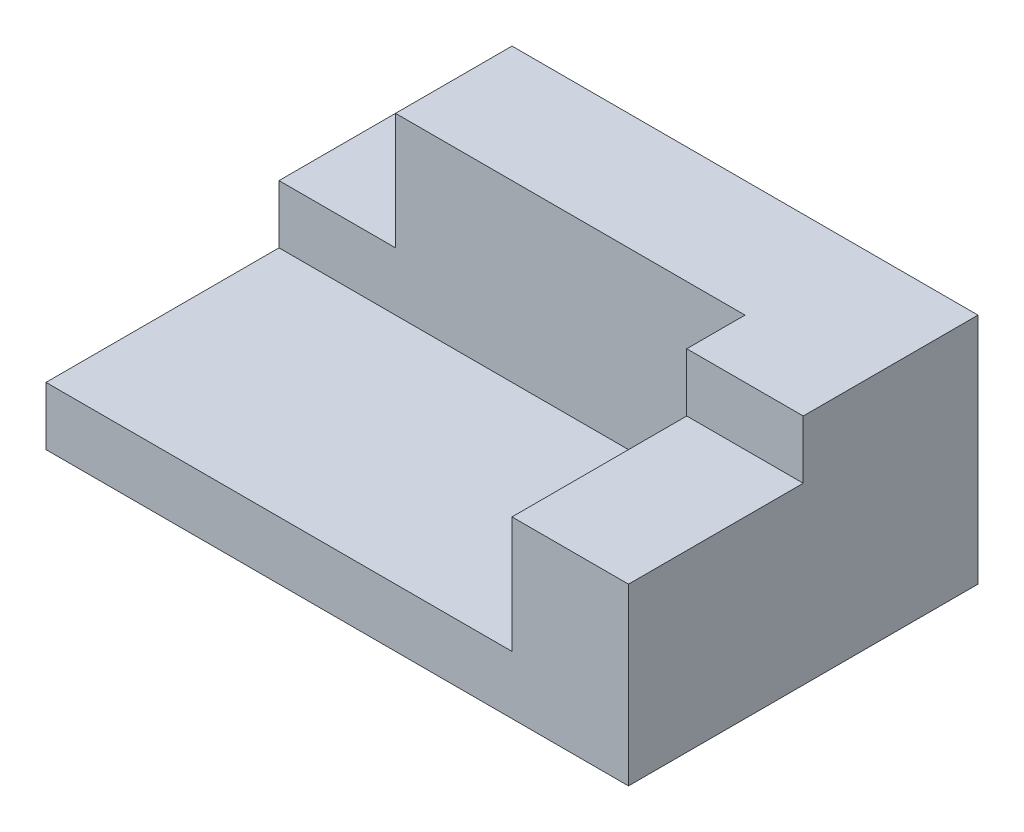
from build123d import *

# Parameters (mm, degrees)
SALIENTE_EXTRUIR1_DEPTH = 10
CROQUIS1_3_W            = 20
CROQUIS1_3_H            = 30
SALIENTE_EXTRUIR2_DEPTH = 30
SALIENTE_EXTRUIR3_DEPTH = 40
CROQUIS1_5_W            = 20
CROQUIS1_5_H            = 20
SALIENTE_EXTRUIR4_DEPTH = 20


with BuildPart() as part:
    # Croquis1 → Saliente-Extruir1 (new body)
    with BuildSketch(Plane(origin=(0, 0, 0), x_dir=(1, 0, 0), z_dir=(0, 1, 0))):
        Polygon((-30, 10), (-50, 10), (-50, -30), (30, -30), (30, 0), (30, 10), align=None)
    extrude(amount=SALIENTE_EXTRUIR1_DEPTH)

    # Croquis1_3 → Saliente-Extruir2 (add)
    with BuildSketch(Plane(origin=(0, 0, 0), x_dir=(1, 0, 0), z_dir=(0, 1, 0))):
        with Locations((40, -15)):
            Rectangle(CROQUIS1_3_W, CROQUIS1_3_H)
    extrude(amount=SALIENTE_EXTRUIR2_DEPTH)

    # Croquis1_4 → Saliente-Extruir3 (add)
    with BuildSketch(Plane(origin=(0, 0, 0), x_dir=(1, 0, 0), z_dir=(0, 1, 0))):
        Polygon((30, 30), (-30, 30), (-30, 10), (30, 10), (30, 0), (50, 0), (50, 30), align=None)
    extrude(amount=SALIENTE_EXTRUIR3_DEPTH)

    # Croquis1_5 → Saliente-Extruir4 (add)
    with BuildSketch(Plane(origin=(0, 0, 0), x_dir=(1, 0, 0), z_dir=(0, 1, 0))):
        with Locations((-40, 20)):
            Rectangle(CROQUIS1_5_W, CROQUIS1_5_H)
    extrude(amount=SALIENTE_EXTRUIR4_DEPTH)


solid = part.part
